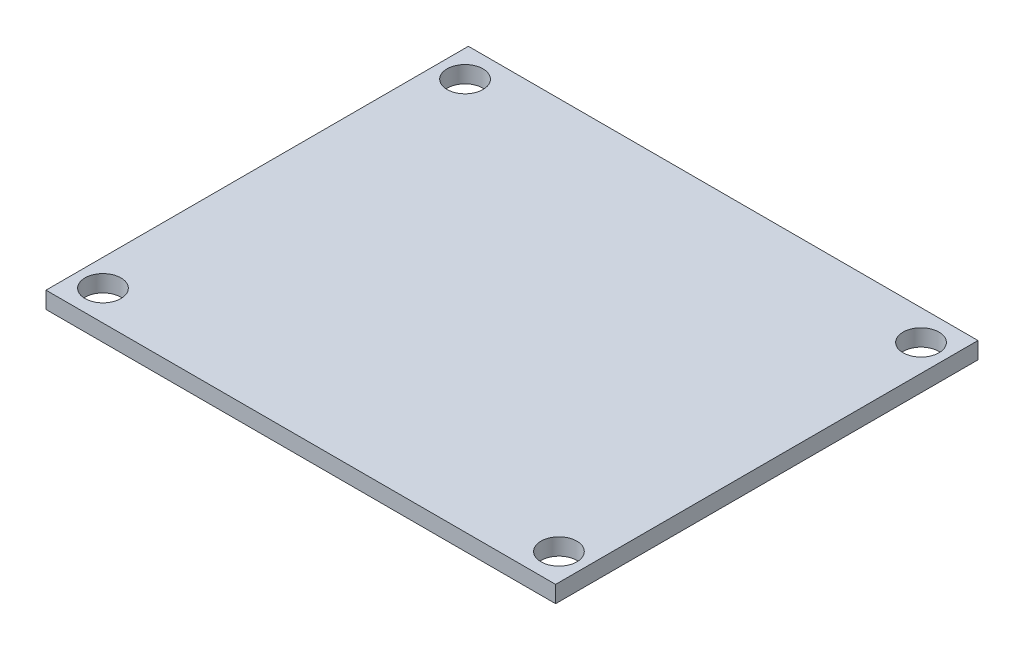
from build123d import *

# Parameters (mm, degrees)
SKETCH1_W            = 48.26
SKETCH1_H            = 40
BOSS_EXTRUDE1_DEPTH  = 1.5875
LPATTERN1_COUNT      = 2
LPATTERN1_PITCH      = 43.18
LPATTERN1_COUNT_DIR2 = 2
LPATTERN1_PITCH_DIR2 = 34.29


with BuildPart() as part:
    # Sketch1 → Boss-Extrude1 (new body)
    with BuildSketch(Plane(origin=(0, 0, 0), x_dir=(1, 0, 0), z_dir=(0, 1, 0))):
        with Locations((-18.638619051, 2.255163759)):
            Rectangle(SKETCH1_W, SKETCH1_H)
    extrude(amount=BOSS_EXTRUDE1_DEPTH)

    # Sketch9 → Clearance hole for 3MM screw (revolve, cut)
    with BuildSketch(Plane(origin=(-40.228619051, 1.5875, -19.400163759), x_dir=(0, 0, 1), z_dir=(1, 0, 0))):
        Polygon((0, 0), (0, 13.721463052), (1.7, 12.7), (1.7, 0), align=None)
    clearance_hole_for_3mm_screw = revolve(axis=Axis((-40.228619051, 7.9375, -19.400163759), (0, -1, 0)), mode=Mode.SUBTRACT)

    # LPattern1: Clearance hole for 3MM screw 2 × 2
    with Locations(*[(i * LPATTERN1_PITCH, 0, j * LPATTERN1_PITCH_DIR2) for i in range(LPATTERN1_COUNT) for j in range(LPATTERN1_COUNT_DIR2) if (i, j) != (0, 0)]):
        add(clearance_hole_for_3mm_screw, mode=Mode.SUBTRACT)


solid = part.part
